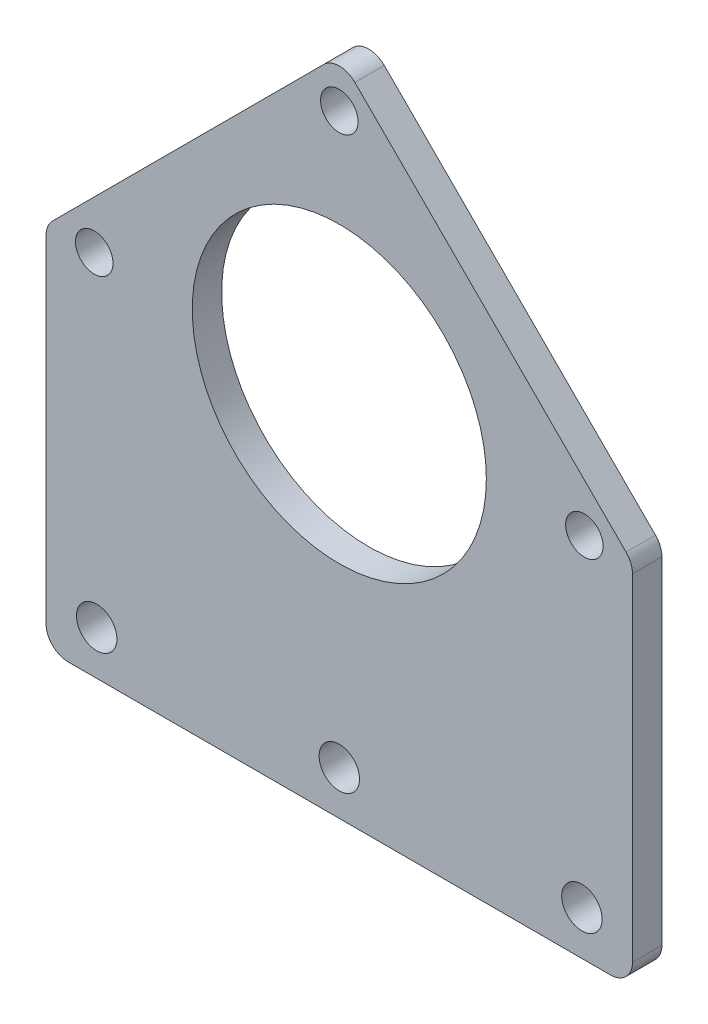
from build123d import *

# Parameters (mm, degrees)
SKETCH_1_R      = 20
SKETCH_1_R_2    = 2.55
SKETCH_1_R_3    = 2.75
EXTRUDE_2_DEPTH = 4
FILLET_1_R      = 3


with BuildPart() as part:
    # Эскиз1 → Бобышка-Вытянуть2 (new body)
    with BuildSketch(Plane.XY):
        Polygon((-39.880822459, 0), (0, 39.880822459), (39.880822459, 0), (39.880822459, -50), (-39.880822459, -50), align=None)
        Circle(SKETCH_1_R, mode=Mode.SUBTRACT)
        with Locations((-33.333013665, 0)):
            Circle(SKETCH_1_R_2, mode=Mode.SUBTRACT)
        with Locations((0, 33.333013665)):
            Circle(SKETCH_1_R_2, mode=Mode.SUBTRACT)
        with Locations((33.333013665, 0)):
            Circle(SKETCH_1_R_2, mode=Mode.SUBTRACT)
        with Locations((-33, -44)):
            Circle(SKETCH_1_R_3, mode=Mode.SUBTRACT)
        with Locations((0, -44)):
            Circle(SKETCH_1_R_3, mode=Mode.SUBTRACT)
        with Locations((33, -44)):
            Circle(SKETCH_1_R_3, mode=Mode.SUBTRACT)
    extrude(amount=EXTRUDE_2_DEPTH)

    # Скругление1
    fillet_1_edges = [part.edges().sort_by_distance(p)[0] for p in [
        (-39.880822459, 0, 2),
        (0, 39.880822459, 2),
        (39.880822459, 0, 2),
        (39.880822459, -50, 2),
        (-39.880822459, -50, 2),
    ]]
    fillet(fillet_1_edges, radius=FILLET_1_R)


solid = part.part
